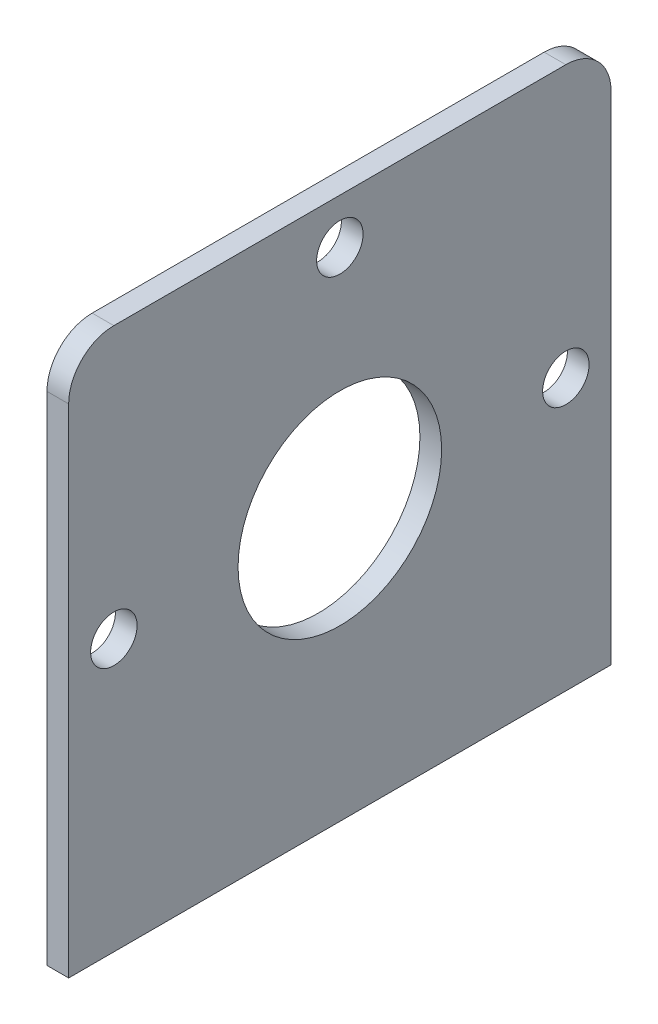
from build123d import *

# Parameters (mm, degrees)
SKETCH1_W                 = 38.1
SKETCH1_H                 = 38.1
SKETCH1_R                 = 7.1501
BOSS_EXTRUDE1_DEPTH       = 1.524
F_4_CLEARANCE_HOLE1_D     = 3.2639
F_4_CLEARANCE_HOLE1_DEPTH = 1.524
FILLET1_R                 = 3.175


with BuildPart() as part:
    # Sketch1 → Boss-Extrude1 (new body)
    with BuildSketch(Plane(origin=(0, 0, 0), x_dir=(0, 0, -1), z_dir=(1, 0, 0))):
        Rectangle(SKETCH1_W, SKETCH1_H)
        Circle(SKETCH1_R, mode=Mode.SUBTRACT)
    extrude(amount=BOSS_EXTRUDE1_DEPTH)

    # #4 Clearance Hole1
    with Locations(Plane(origin=(1.524, 0, 0), x_dir=(0, 0, -1), z_dir=(1, 0, 0))):
        with Locations((-15.875, 0), (15.875, 0), (0, 15.875)):
            Hole(F_4_CLEARANCE_HOLE1_D / 2, depth=F_4_CLEARANCE_HOLE1_DEPTH)

    # Fillet1
    fillet1_edges = [part.edges().sort_by_distance(p)[0] for p in [
        (0.762, 19.05, 19.05),
        (0.762, 19.05, -19.05),
    ]]
    fillet(fillet1_edges, radius=FILLET1_R)


solid = part.part
